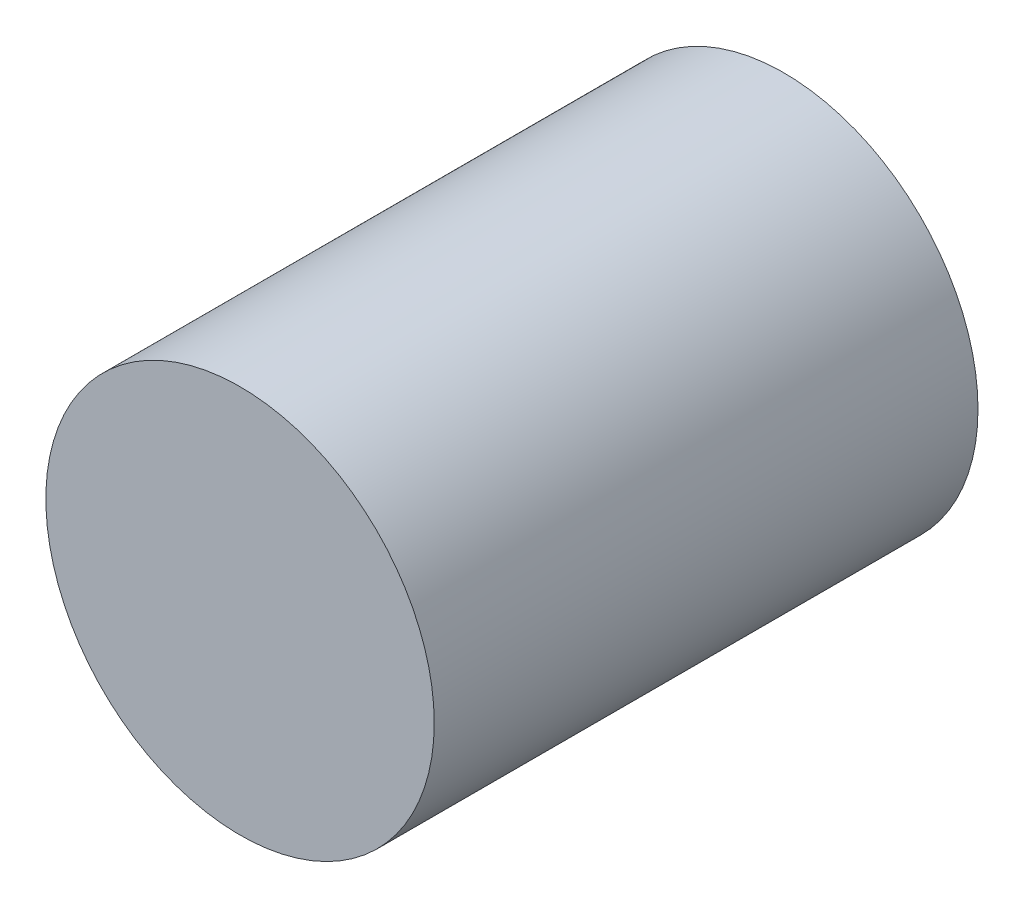
from build123d import *

# Parameters (mm, degrees)
SKETCH1_R           = 50
BOSS_EXTRUDE1_DEPTH = 140
SKETCH4_R           = 30
CUT_EXTRUDE1_DEPTH  = 40
SKETCH5_R           = 10
CUT_EXTRUDE2_DEPTH  = 120


with BuildPart() as part:
    # Sketch1 → Boss-Extrude1 (new body)
    with BuildSketch(Plane.XY):
        Circle(SKETCH1_R)
    extrude(amount=BOSS_EXTRUDE1_DEPTH)

    # Sketch4 → Cut-Extrude1 (cut)
    with BuildSketch(Plane(origin=(0, 0, 0), x_dir=(-1, 0, 0), z_dir=(0, 0, -1))):
        Circle(SKETCH4_R)
    extrude(amount=-CUT_EXTRUDE1_DEPTH, mode=Mode.SUBTRACT)

    # Sketch5 → Cut-Extrude2 (cut)
    with BuildSketch(Plane(origin=(0, 0, 0), x_dir=(-1, 0, 0), z_dir=(0, 0, -1))):
        Circle(SKETCH5_R)
    extrude(amount=-CUT_EXTRUDE2_DEPTH, mode=Mode.SUBTRACT)


solid = part.part
